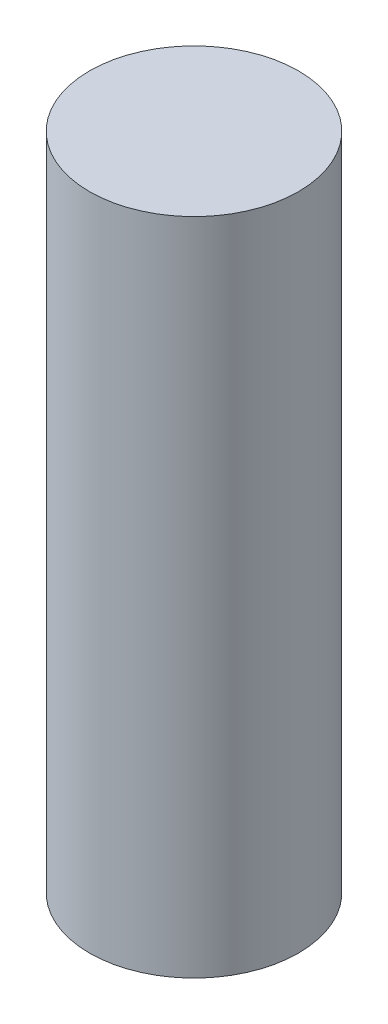
from build123d import *

# Parameters (mm, degrees)
SKETCH1_R      = 6.5
EXTRUDE1_DEPTH = 41


with BuildPart() as part:
    # Sketch1 → Extrude1 (new body)
    with BuildSketch(Plane(origin=(0, 0, 0), x_dir=(1, 0, 0), z_dir=(0, 1, 0))):
        with Locations(Location((0, 0, 0), (0, 0, 270))):  # turned: the seam where the file's is
            Circle(SKETCH1_R)
    extrude(amount=-EXTRUDE1_DEPTH)


solid = part.part
